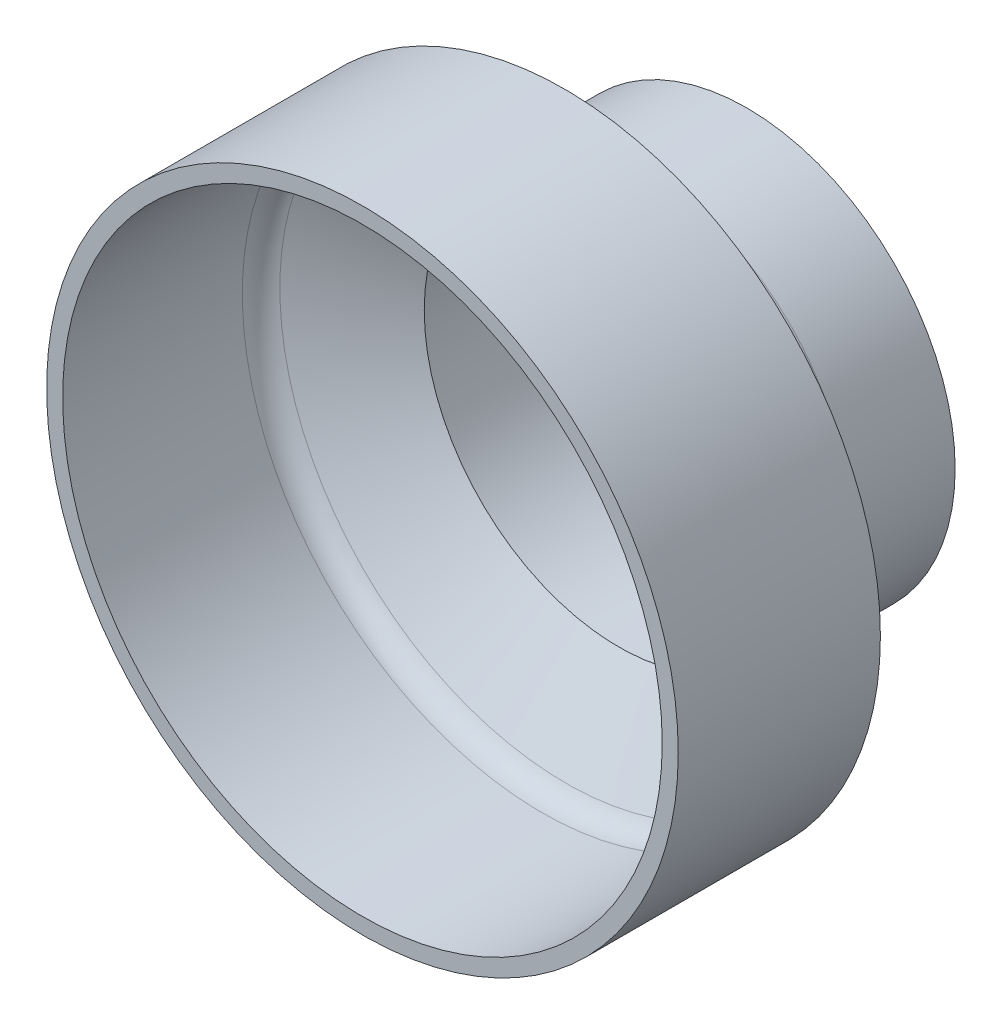
from build123d import *


with BuildPart() as part:
    # Sketch1 → Revolve1 (revolve)
    with BuildSketch(Plane(origin=(0, 0, 0), x_dir=(1, 0, 0), z_dir=(0, 1, 0))):
        with BuildLine():
            Line((6.35, -0.762), (10.795, -0.762))
            Line((10.795, -0.762), (10.795, -7.112))
            Line((10.795, -7.112), (15.875, -10.044939367))
            ThreePointArc((15.875, -10.044939367), (16.432822715, -10.602762083), (16.637, -11.364762083))
            Line((16.637, -11.364762083), (16.637, -21.336))
            Line((16.637, -21.336), (17.526, -21.336))
            Line((17.526, -21.336), (17.526, -10.118262852))
            Line((17.526, -10.118262852), (12.319, -7.112))
            ThreePointArc((12.319, -7.112), (11.761177285, -6.554177285), (11.557, -5.792177285))
            Line((11.557, -5.792177285), (11.557, 0))
            Line((11.557, 0), (6.35, 0))
            Line((6.35, 0), (6.35, -0.762))
        make_face()
    revolve(axis=Axis((0, 0, 0), (0, 0, 1)))


solid = part.part
